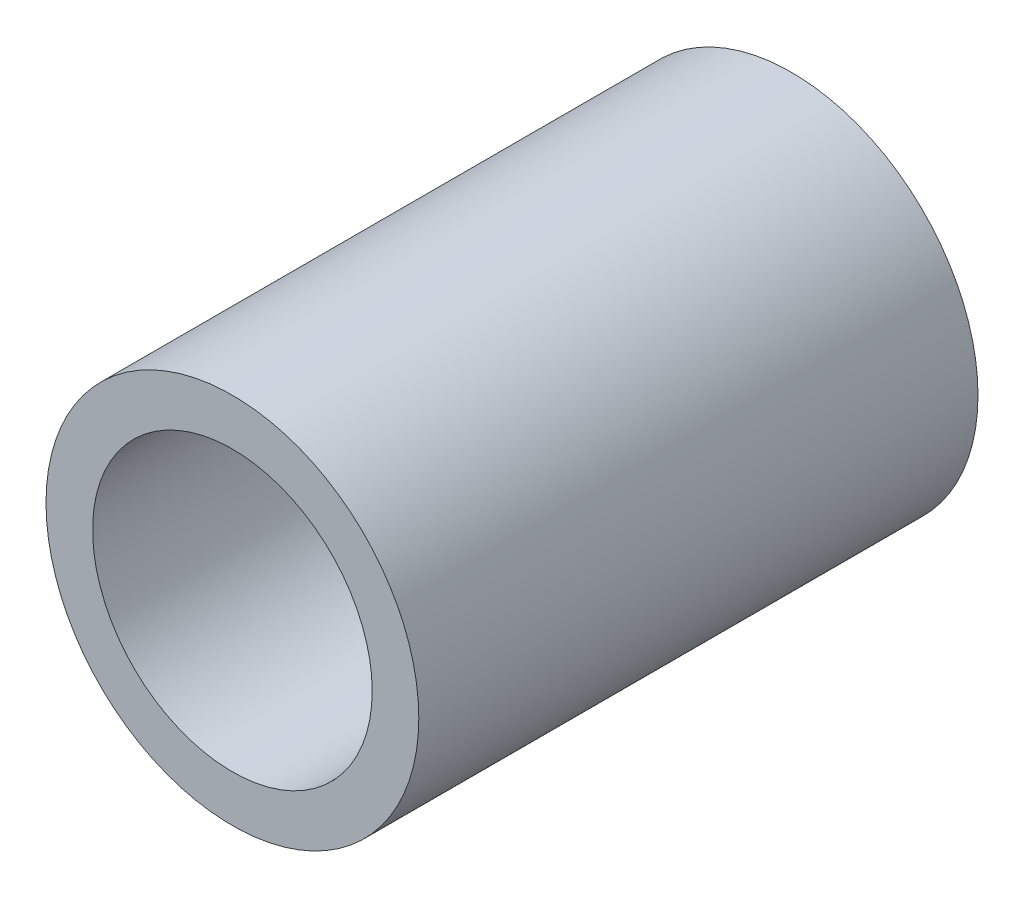
from build123d import *

# Parameters (mm, degrees)
SKETCH1_R           = 20
BOSS_EXTRUDE1_DEPTH = 60
SKETCH2_R           = 15
CUT_EXTRUDE1_DEPTH  = 58


with BuildPart() as part:
    # Sketch1 → Boss-Extrude1 (new body)
    with BuildSketch(Plane.XY):
        Circle(SKETCH1_R)
    extrude(amount=BOSS_EXTRUDE1_DEPTH)

    # Sketch2 → Cut-Extrude1 (cut)
    with BuildSketch(Plane.XY.offset(60)):
        Circle(SKETCH2_R)
    extrude(amount=-CUT_EXTRUDE1_DEPTH, mode=Mode.SUBTRACT)


solid = part.part
